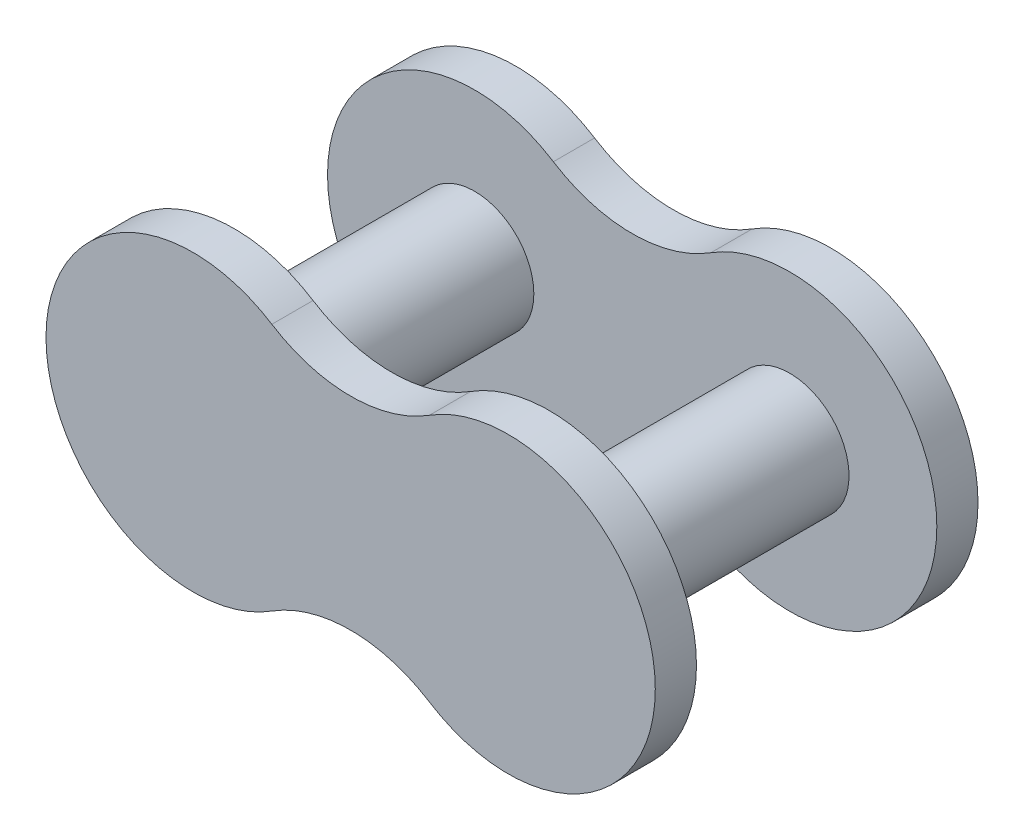
from build123d import *

# Parameters (mm, degrees)
SKETCH1_R             = 1.7907
BOSS_EXTRUDE1_DEPTH   = 3.6322
BOSS_EXTRUDE1_2_DEPTH = 3.6322
BOSS_EXTRUDE2_DEPTH   = 1.2446


with BuildPart() as part:
    # Sketch1 → Boss-Extrude1 (new body, symmetric)
    with BuildSketch(Plane.XY):
        with Locations((-4.7625, 0)):
            Circle(SKETCH1_R)
    extrude(amount=BOSS_EXTRUDE1_DEPTH, both=True)



with BuildPart() as body_2:
    # Sketch1 → Boss-Extrude1 2 (new body, symmetric)
    with BuildSketch(Plane.XY):
        with Locations((4.7625, 0)):
            Circle(SKETCH1_R)
    extrude(amount=BOSS_EXTRUDE1_2_DEPTH, both=True)


with BuildPart() as part_1:
    add(part.part)

    add(body_2.part)  # Boss-Extrude2 merges body 2
    # Sketch3 → Boss-Extrude2 (add)
    with BuildSketch(Plane.XY.offset(3.6322)):
        with BuildLine():
            ThreePointArc((-2.38125, 3.753354958), (-9.2075, 0), (-2.38125, -3.753354958))
            ThreePointArc((-2.38125, -3.753354958), (0, -3.061709915), (2.38125, -3.753354958))
            ThreePointArc((2.38125, -3.753354958), (9.2075, 0), (2.38125, 3.753354958))
            ThreePointArc((2.38125, 3.753354958), (0, 3.061709915), (-2.38125, 3.753354958))
        make_face()
    boss_extrude2 = extrude(amount=BOSS_EXTRUDE2_DEPTH)

    # Mirror1: Boss-Extrude2 across plane
    add(boss_extrude2.mirror(Plane.XY))


solid = part_1.part
